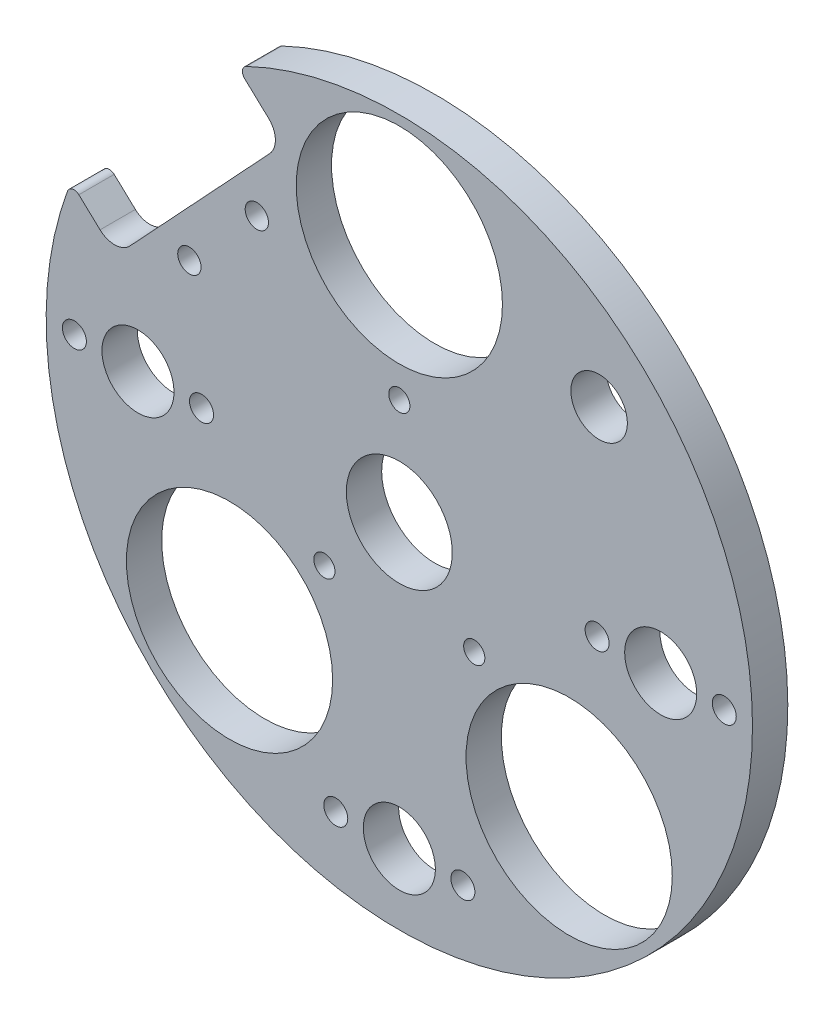
from build123d import *

# Parameters (mm, degrees)
SKETCH1_R                    = 50
BOSS_EXTRUDE1_DEPTH          = 5
F_15_0_15_DIAMETER_HOLE1_D   = 15
F_10_2_10_2_DIAMETER_HOLE1_D = 10.2
M3_CLEARANCE_HOLE1_D         = 3.4
SKETCH9_R                    = 14.6
SKETCH9_R_2                  = 1.5
CUT_EXTRUDE1_DEPTH           = 10
SKETCH10_R                   = 1.65
CUT_EXTRUDE2_DEPTH           = 5
SKETCH11_R                   = 4
CUT_EXTRUDE3_DEPTH           = 10
FILLET1_R                    = 1


with BuildPart() as part:
    # Sketch1 → Boss-Extrude1 (new body)
    with BuildSketch(Plane.XY):
        Circle(SKETCH1_R)
    extrude(amount=BOSS_EXTRUDE1_DEPTH)

    # Ø15.0 (15) Diameter Hole1 (through all)
    with Locations(Plane(origin=(0, 0, 0), x_dir=(-1, 0, 0), z_dir=(0, 0, -1))):
        with Locations((0, 0)):
            Hole(F_15_0_15_DIAMETER_HOLE1_D / 2)

    # Ø10.2 (10.2) Diameter Hole1 (through all)
    with Locations(Plane(origin=(0, 0, 0), x_dir=(-1, 0, 0), z_dir=(0, 0, -1))):
        with Locations((37, 0), (-37, 0), (0, -40)):
            Hole(F_10_2_10_2_DIAMETER_HOLE1_D / 2)

    # M3 Clearance Hole1 (through all)
    with Locations(Plane.XY.offset(5)):
        with Locations((46, 0), (28, 0), (9, -40), (-9, -40), (-46, 0), (-28, 0)):
            Hole(M3_CLEARANCE_HOLE1_D / 2)

    # Sketch9 → Cut-Extrude1 (cut)
    with BuildSketch(Plane.XY.offset(5)):
        with Locations((24.04163056, -24.04163056)):
            Circle(SKETCH9_R)
        with Locations((10.606601718, -10.606601718)):
            Circle(SKETCH9_R_2)
        with Locations((-24.04163056, -24.04163056)):
            Circle(SKETCH9_R)
        with Locations((-10.606601718, -10.606601718)):
            Circle(SKETCH9_R_2)
        with Locations((0, 34)):
            Circle(SKETCH9_R)
        with Locations((0, 15)):
            Circle(SKETCH9_R_2)
    extrude(amount=-CUT_EXTRUDE1_DEPTH, mode=Mode.SUBTRACT)

    # Sketch10 → Cut-Extrude2 (cut)
    with BuildSketch(Plane.XY.offset(5)):
        with Locations((-20.17442319, 27.477446333)):
            Circle(SKETCH10_R)
        with Locations((-29.722400231, 17.23849451)):
            Circle(SKETCH10_R)
        with BuildLine():
            Line((-27.274837591, 48.455628221), (-18.498593172, 40.2716479))
            ThreePointArc((-18.498593172, 40.2716479), (-17.546415771, 38.182285285), (-18.350527147, 36.031591715))
            Line((-18.350527147, 36.031591715), (-38.128479589, 14.822334368))
            ThreePointArc((-38.128479589, 14.822334368), (-40.217842204, 13.870156967), (-42.368535774, 14.674268343))
            Line((-42.368535774, 14.674268343), (-51.144780194, 22.858248664))
            Line((-51.144780194, 22.858248664), (-27.274837591, 48.455628221))
        make_face()
    extrude(amount=-CUT_EXTRUDE2_DEPTH, mode=Mode.SUBTRACT)

    # Sketch11 → Cut-Extrude3 (cut)
    with BuildSketch(Plane.XY.offset(5)):
        with Locations((28.284271247, 28.284271247)):
            Circle(SKETCH11_R)
    extrude(amount=-CUT_EXTRUDE3_DEPTH, mode=Mode.SUBTRACT)

    # Fillet1
    fillet1_edges = [part.edges().sort_by_distance(p)[0] for p in [
        (-46.456878561, 18.486709669, 2.5),
        (-22.949421323, 44.422112297, 2.5),
    ]]
    fillet(fillet1_edges, radius=FILLET1_R)


solid = part.part
